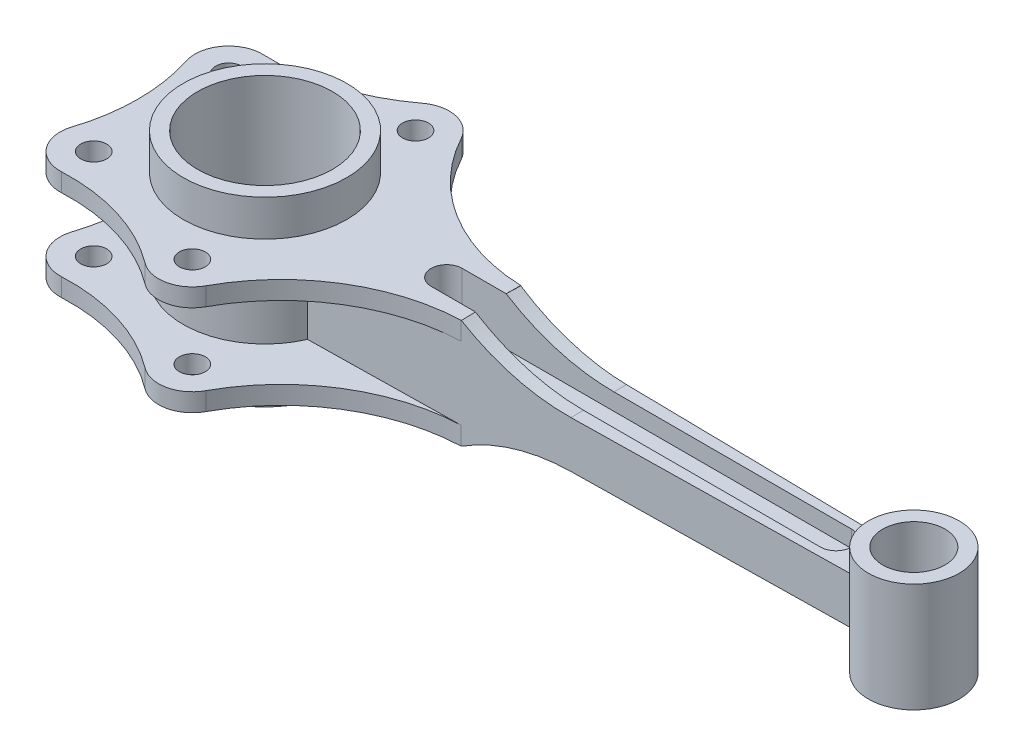
from build123d import *

# Parameters (mm, degrees)
SWEEP2_PROFILE_R     = 31.5
BOSS_EXTRUDE2_DEPTH  = 21
CUT_EXTRUDE4_REACH   = 47.019
SWEEP4_PROFILE_R     = 17.5
CUT_EXTRUDE5_START   = 2.5
CUT_EXTRUDE5_DEPTH   = 18.5
BOSS_EXTRUDE5_START  = 21
SKETCH47_R           = 5
BOSS_EXTRUDE5_DEPTH  = 7
BOSS_EXTRUDE6_START  = -21
SKETCH47_3_R         = 5
BOSS_EXTRUDE6_DEPTH  = 7
CUT_SWEEP1_PROFILE_R = 26
CUT_SWEEP2_PROFILE_R = 12


with BuildPart() as part:
    # Sweep2: sweep along a path in Sketch1
    with BuildLine(Plane.XY) as sweep2_path:
        Line((0, 35), (0, -35))
    # Sweep2 profile (on start of the path) → Sweep2 (sweep)
    with BuildSketch(Plane(origin=(0, 35, 0), x_dir=(-1, 0, 0), z_dir=(0, -1, 0))):
        Circle(SWEEP2_PROFILE_R)
    sweep(path=sweep2_path.line)

    # Sketch22 → Boss-Extrude2 (add, symmetric)
    with BuildSketch(Plane(origin=(0, 0, 0), x_dir=(1, 0, 0), z_dir=(0, 1, 0))):
        Polygon((0, 13), (240, 9), (240, -9), (0, -13), align=None)
    extrude(amount=BOSS_EXTRUDE2_DEPTH, both=True)

    # Sketch34 → Cut-Extrude4 (cut, up to next)
    with BuildSketch(Plane(origin=(0.216606498, 0, 12.996389892), x_dir=(0.99986114, 0, -0.016664352), z_dir=(0.016664352, 0, 0.99986114)), mode=Mode.PRIVATE) as cut_extrude4_sk1:
        with BuildLine():
            Line((87, 21), (243, 21))
            Line((243, 21), (243, 9))
            Line((243, 9), (128.569219382, 9))
            ThreePointArc((128.569219382, 9), (106.935911729, 12.060024019), (87, 21))
        make_face()
    cut_extrude4_tool1 = extrude(cut_extrude4_sk1.sketch, amount=-CUT_EXTRUDE4_REACH, mode=Mode.PRIVATE) & part.part
    add(cut_extrude4_tool1.solids().sort_by_distance((171.561444, 15.230505, 10.140643))[0], mode=Mode.SUBTRACT)
    # Sketch34 → Cut-Extrude4 (cut, up to next)
    with BuildSketch(Plane(origin=(0.216606498, 0, 12.996389892), x_dir=(0.99986114, 0, -0.016664352), z_dir=(0.016664352, 0, 0.99986114)), mode=Mode.PRIVATE) as cut_extrude4_sk2:
        with BuildLine():
            Line((128.569219382, -9), (243, -9))
            Line((243, -9), (243, -21))
            Line((243, -21), (87, -21))
            ThreePointArc((87, -21), (106.935911729, -12.060024019), (128.569219382, -9))
        make_face()
    cut_extrude4_tool2 = extrude(cut_extrude4_sk2.sketch, amount=-CUT_EXTRUDE4_REACH, mode=Mode.PRIVATE) & part.part
    add(cut_extrude4_tool2.solids().sort_by_distance((171.561444, -15.230505, 10.140643))[0], mode=Mode.SUBTRACT)

    # Sweep4: sweep along a path in Sketch35
    with BuildLine(Plane.XY) as sweep4_path:
        Line((250, 21), (250, -21))
    # Sweep4 profile (on start of the path) → Sweep4 (sweep)
    with BuildSketch(Plane(origin=(250, 21, 0), x_dir=(0, 0, -1), z_dir=(0, -1, 0))):
        Circle(SWEEP4_PROFILE_R)
    sweep(path=sweep4_path.line)

    # Sketch43 → Cut-Extrude5 (cut)
    with BuildSketch(Plane(origin=(0, 0, 0), x_dir=(1, 0, 0), z_dir=(0, 1, 0)).offset(CUT_EXTRUDE5_START)):
        with BuildLine():
            Line((70, 6), (220, 6))
            ThreePointArc((220, 6), (226, 0), (220, -6))
            Line((220, -6), (70, -6))
            ThreePointArc((70, -6), (64, 0), (70, 6))
        make_face()
    cut_extrude5 = extrude(amount=CUT_EXTRUDE5_DEPTH, mode=Mode.SUBTRACT)

    # Mirror2: Cut-Extrude5 across plane
    add(cut_extrude5.mirror(Plane.ZX), mode=Mode.SUBTRACT)

    # Sketch47 → Boss-Extrude5 (add)
    with BuildSketch(Plane(origin=(0, 0, 0), x_dir=(1, 0, 0), z_dir=(0, 1, 0)).offset(BOSS_EXTRUDE5_START)):
        with BuildLine():
            Line((87, -6), (87, -11.55))
            ThreePointArc((87, -11.55), (51.726774535, -22.345969003), (26.429629343, -49.193833472))
            ThreePointArc((26.429629343, -49.193833472), (17.766830002, -55.702151461), (7.181946677, -53.386435492))
            ThreePointArc((7.181946677, -53.386435492), (-14.855989459, -42.122318837), (-39.406288617, -38.986435492))
            ThreePointArc((-39.406288617, -38.986435492), (-50.326951915, -33.896458963), (-52.376901133, -22.023529412))
            ThreePointArc((-52.376901133, -22.023529412), (-48.925892025, 0), (-52.376901133, 22.023529412))
            ThreePointArc((-52.376901133, 22.023529412), (-50.326951915, 33.896458963), (-39.406288617, 38.986435492))
            ThreePointArc((-39.406288617, 38.986435492), (-14.855989459, 42.122318837), (7.181946677, 53.386435492))
            ThreePointArc((7.181946677, 53.386435492), (17.766830002, 55.702151461), (26.429629343, 49.193833472))
            ThreePointArc((26.429629343, 49.193833472), (51.726774535, 22.345969003), (87, 11.55))
            Line((87, 11.55), (86.912082494, 6))
            Line((86.912082494, 6), (70, 6))
            ThreePointArc((70, 6), (64, 0), (70, -6))
            Line((70, -6), (87, -6))
        make_face()
        with Locations((15, 43)):
            Circle(SKETCH47_R, mode=Mode.SUBTRACT)
        with Locations((-40, 26)):
            Circle(SKETCH47_R, mode=Mode.SUBTRACT)
        with Locations((-40, -26)):
            Circle(SKETCH47_R, mode=Mode.SUBTRACT)
        with Locations((15, -43)):
            Circle(SKETCH47_R, mode=Mode.SUBTRACT)
    extrude(amount=-BOSS_EXTRUDE5_DEPTH)

    # Sketch47_3 → Boss-Extrude6 (add)
    with BuildSketch(Plane(origin=(0, 0, 0), x_dir=(1, 0, 0), z_dir=(0, 1, 0)).offset(BOSS_EXTRUDE6_START)):
        with BuildLine():
            Line((87, -6), (87, -11.55))
            ThreePointArc((87, -11.55), (51.726774535, -22.345969003), (26.429629343, -49.193833472))
            ThreePointArc((26.429629343, -49.193833472), (17.766830002, -55.702151461), (7.181946677, -53.386435492))
            ThreePointArc((7.181946677, -53.386435492), (-14.855989459, -42.122318837), (-39.406288617, -38.986435492))
            ThreePointArc((-39.406288617, -38.986435492), (-50.326951915, -33.896458963), (-52.376901133, -22.023529412))
            ThreePointArc((-52.376901133, -22.023529412), (-48.925892025, 0), (-52.376901133, 22.023529412))
            ThreePointArc((-52.376901133, 22.023529412), (-50.326951915, 33.896458963), (-39.406288617, 38.986435492))
            ThreePointArc((-39.406288617, 38.986435492), (-14.855989459, 42.122318837), (7.181946677, 53.386435492))
            ThreePointArc((7.181946677, 53.386435492), (17.766830002, 55.702151461), (26.429629343, 49.193833472))
            ThreePointArc((26.429629343, 49.193833472), (51.726774535, 22.345969003), (87, 11.55))
            Line((87, 11.55), (86.912082494, 6))
            Line((86.912082494, 6), (70, 6))
            ThreePointArc((70, 6), (64, 0), (70, -6))
            Line((70, -6), (87, -6))
        make_face()
        with Locations((15, 43)):
            Circle(SKETCH47_3_R, mode=Mode.SUBTRACT)
        with Locations((-40, 26)):
            Circle(SKETCH47_3_R, mode=Mode.SUBTRACT)
        with Locations((-40, -26)):
            Circle(SKETCH47_3_R, mode=Mode.SUBTRACT)
        with Locations((15, -43)):
            Circle(SKETCH47_3_R, mode=Mode.SUBTRACT)
    extrude(amount=BOSS_EXTRUDE6_DEPTH)

    # Cut-Sweep1: sweep along a path in Sketch1_4
    with BuildLine(Plane.XY) as cut_sweep1_path:
        Line((0, 35), (0, -35))
    # Cut-Sweep1 profile (on start of the path) → Cut-Sweep1 (sweep, cut)
    with BuildSketch(Plane(origin=(0, 35, 0), x_dir=(-1, 0, 0), z_dir=(0, -1, 0))):
        Circle(CUT_SWEEP1_PROFILE_R)
    sweep(path=cut_sweep1_path.line, mode=Mode.SUBTRACT)

    # Cut-Sweep2: sweep along a path in Sketch35_2
    with BuildLine(Plane.XY) as cut_sweep2_path:
        Line((250, 21), (250, -21))
    # Cut-Sweep2 profile (on start of the path) → Cut-Sweep2 (sweep, cut)
    with BuildSketch(Plane(origin=(250, 21, 0), x_dir=(0, 0, -1), z_dir=(0, -1, 0))):
        Circle(CUT_SWEEP2_PROFILE_R)
    sweep(path=cut_sweep2_path.line, mode=Mode.SUBTRACT)


solid = part.part
